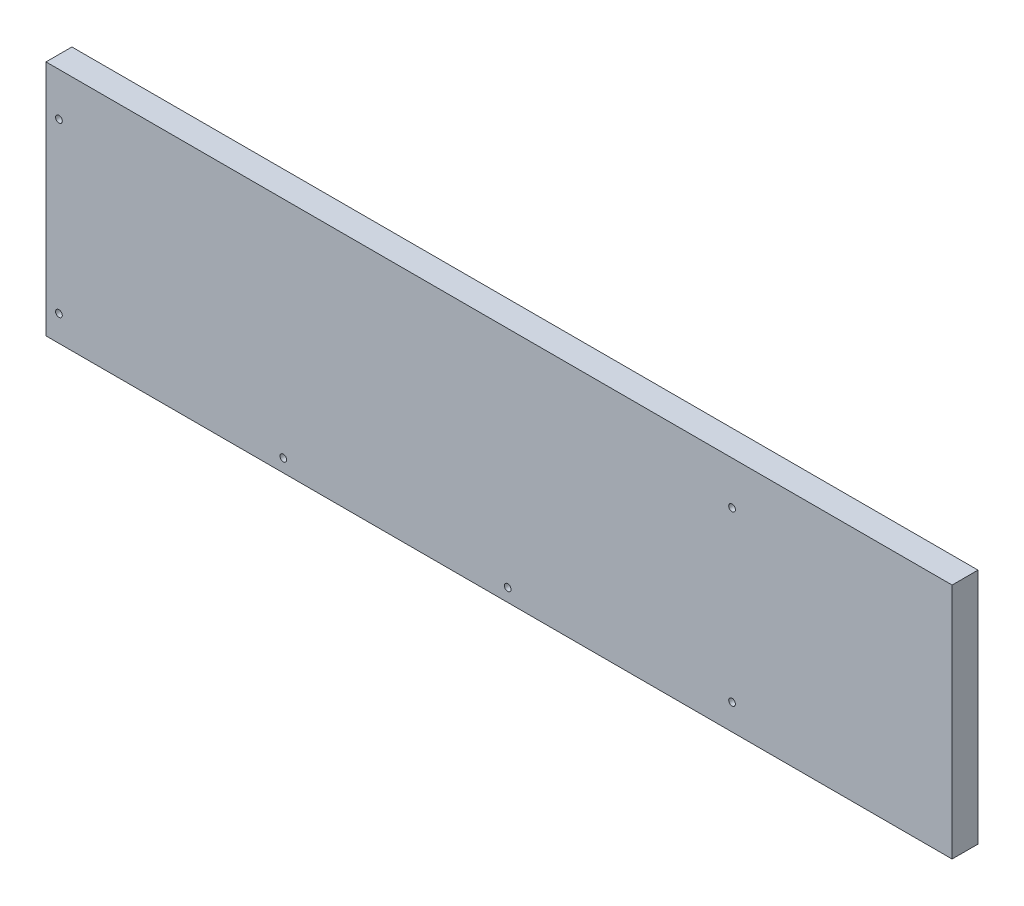
from build123d import *

# Parameters (mm, degrees)
SKETCH1_W           = 420
SKETCH1_H           = 110
BOSS_EXTRUDE1_DEPTH = 12
SKETCH2_R           = 1.55
CUT_EXTRUDE2_DEPTH  = 13


with BuildPart() as part:
    # Sketch1 → Boss-Extrude1 (new body)
    with BuildSketch(Plane.XY):
        Rectangle(SKETCH1_W, SKETCH1_H)
    extrude(amount=BOSS_EXTRUDE1_DEPTH)

    # Sketch2 → Cut-Extrude2 (cut, through all)
    with BuildSketch(Plane.XY.offset(12)):
        with Locations((-204, 35)):
            Circle(SKETCH2_R)
        with Locations((-204, -43)):
            Circle(SKETCH2_R)
        with Locations((-100, -49)):
            Circle(SKETCH2_R)
        with Locations((4, -49)):
            Circle(SKETCH2_R)
        with Locations((108, -43)):
            Circle(SKETCH2_R)
        with Locations((108, 35)):
            Circle(SKETCH2_R)
    extrude(amount=-CUT_EXTRUDE2_DEPTH, mode=Mode.SUBTRACT)


solid = part.part
